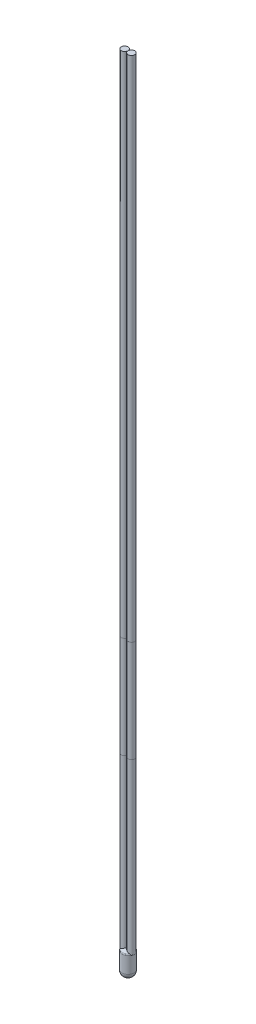
from build123d import *

# Parameters (mm, degrees)
REDONDEO1_R               = 0.2
CROQUIS2_R                = 0.5
SALIENTE_EXTRUIR1_DEPTH   = 25
SALIENTE_EXTRUIR6_START   = -25
CROQUIS2_3_R              = 0.5
SALIENTE_EXTRUIR6_DEPTH   = 15
SALIENTE_EXTRUIR6_2_DEPTH = 15
SALIENTE_EXTRUIR7_START   = -40
CROQUIS2_4_R              = 0.5
SALIENTE_EXTRUIR7_DEPTH   = 75
SALIENTE_EXTRUIR7_2_DEPTH = 75


with BuildPart() as part:
    # Croquis1 → Revoluci_n2 (revolve)
    with BuildSketch(Plane.XY):
        with BuildLine():
            Line((0, 0), (0, 2.5))
            ThreePointArc((0, 2.5), (0.411039098, 2.782931151), (0.9, 2.882532421))
            Line((0.9, 2.882532421), (0.9, -0.9))
            ThreePointArc((0.9, -0.9), (0.263603897, -0.636396103), (0, 0))
        make_face()
    revolve(axis=Axis((0.9, 2.882532421, 0), (0, -1, 0)))

    # Redondeo1
    redondeo1_edges = [part.edges().sort_by_distance(p)[0] for p in [
        (1.8, 2.5, 0),
    ]]
    fillet(redondeo1_edges, radius=REDONDEO1_R)

    # Croquis2 → Saliente-Extruir1 (add)
    with BuildSketch(Plane(origin=(0, 2.415156213, 0), x_dir=(-1, 0, 0), z_dir=(0, -1, 0))):
        with Locations((-1.41, 0)):
            Circle(CROQUIS2_R)
        with Locations((-0.4, 0)):
            Circle(CROQUIS2_R)
    extrude(amount=-SALIENTE_EXTRUIR1_DEPTH)


with BuildPart() as body_2:
    # Croquis2_3 → Saliente-Extruir6 (new body)
    with BuildSketch(Plane(origin=(0, 2.415156213, 0), x_dir=(-1, 0, 0), z_dir=(0, -1, 0)).offset(SALIENTE_EXTRUIR6_START)):
        with Locations((-1.41, 0)):
            Circle(CROQUIS2_3_R)
    extrude(amount=-SALIENTE_EXTRUIR6_DEPTH)


with BuildPart() as body_3:
    # Croquis2_3 → Saliente-Extruir6 2 (new body)
    with BuildSketch(Plane(origin=(0, 2.415156213, 0), x_dir=(-1, 0, 0), z_dir=(0, -1, 0)).offset(SALIENTE_EXTRUIR6_START)):
        with Locations((-0.4, 0)):
            Circle(CROQUIS2_3_R)
    extrude(amount=-SALIENTE_EXTRUIR6_2_DEPTH)


with BuildPart() as body_4:
    # Croquis2_4 → Saliente-Extruir7 (new body)
    with BuildSketch(Plane(origin=(0, 2.415156213, 0), x_dir=(-1, 0, 0), z_dir=(0, -1, 0)).offset(SALIENTE_EXTRUIR7_START)):
        with Locations((-1.41, 0)):
            Circle(CROQUIS2_4_R)
    extrude(amount=-SALIENTE_EXTRUIR7_DEPTH)


with BuildPart() as body_5:
    # Croquis2_4 → Saliente-Extruir7 2 (new body)
    with BuildSketch(Plane(origin=(0, 2.415156213, 0), x_dir=(-1, 0, 0), z_dir=(0, -1, 0)).offset(SALIENTE_EXTRUIR7_START)):
        with Locations((-0.4, 0)):
            Circle(CROQUIS2_4_R)
    extrude(amount=-SALIENTE_EXTRUIR7_2_DEPTH)


solid = Compound([part.part, body_2.part, body_3.part, body_4.part, body_5.part])
